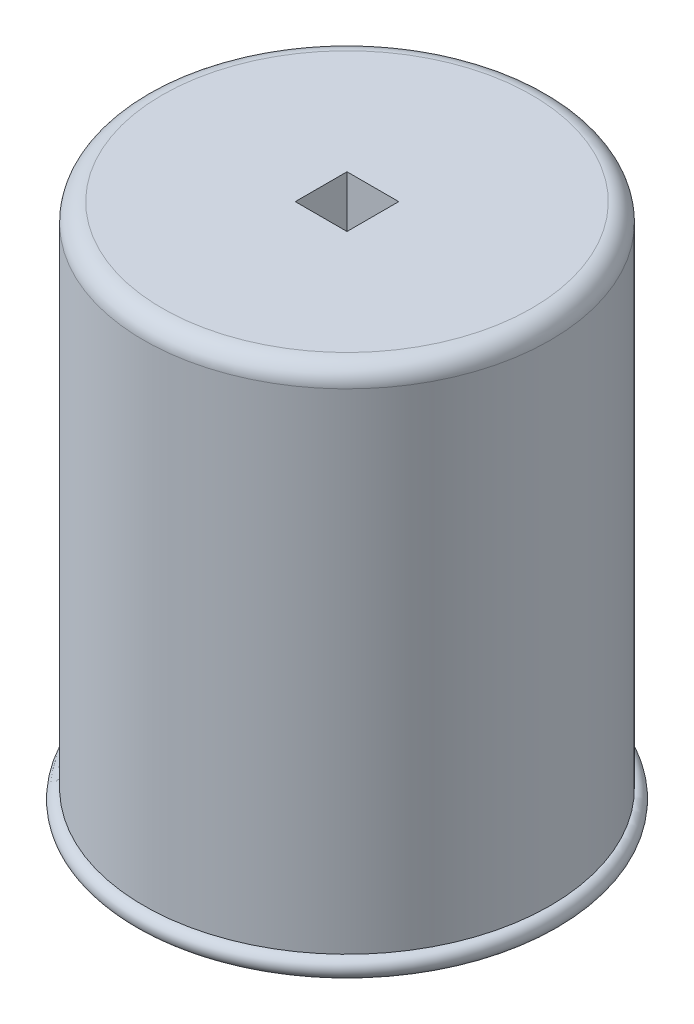
from build123d import *

# Parameters (mm, degrees)
CUT_EXTRUDE2_REACH = 287
SKETCH3_W          = 28
SKETCH3_H          = 28
CUT_EXTRUDE3_DEPTH = 60
CUT_EXTRUDE4_REACH = 191
SKETCH7_W          = 5
SKETCH7_H          = 5
FILLET1_R          = 10


with BuildPart() as part:
    # Sketch1 → Revolve2 (revolve)
    with BuildSketch(Plane.XY):
        with BuildLine():
            Line((0, 0), (0, 40))
            Line((0, 40), (-110, 40))
            Line((-110, 40), (-110, -235))
            ThreePointArc((-110, -235), (-113.535533906, -243.535533906), (-105, -240))
            Line((-105, -240), (-105, 35))
            Line((-105, 35), (-28, 35))
            Line((-28, 35), (-28, -225))
            Line((-28, -225), (-5, -225))
            Line((-5, -225), (-5, -220))
            Line((-5, -220), (-23, -220))
            Line((-23, -220), (-23, -149))
            Line((-23, -149), (-5, -149))
            Line((-5, -149), (-5, -144))
            Line((-5, -144), (-23, -144))
            Line((-23, -144), (-23, 0))
            Line((-23, 0), (0, 0))
        make_face()
    revolve(axis=Axis((0, 0, 0), (0, 1, 0)))

    # Sketch3 → Cut-Extrude2 (cut, up to next)
    with BuildSketch(Plane(origin=(0, 40, 0), x_dir=(1, 0, 0), z_dir=(0, 1, 0)), mode=Mode.PRIVATE) as cut_extrude2_sk1:
        Rectangle(SKETCH3_W, SKETCH3_H)
    cut_extrude2_tool1 = extrude(cut_extrude2_sk1.sketch, amount=-CUT_EXTRUDE2_REACH, mode=Mode.PRIVATE) & part.part
    add(cut_extrude2_tool1.solids().sort_by_distance((0, 40, 0))[0], mode=Mode.SUBTRACT)

    # Sketch6 → Cut-Extrude3 (cut)
    with BuildSketch(Plane(origin=(0, -214.5, 0), x_dir=(1, 0, 0), z_dir=(0, 1, 0))):
        with BuildLine():
            Line((0, -28), (0, -25.5))
            ThreePointArc((0, -25.5), (3.720216095, -25.22716774), (7.360824742, -24.414509193))
            Line((7.360824742, -24.414509193), (6.639175258, -22.02092986))
            ThreePointArc((6.639175258, -22.02092986), (23, 0), (6.639175258, 22.02092986))
            Line((6.639175258, 22.02092986), (7.360824742, 24.414509193))
            ThreePointArc((7.360824742, 24.414509193), (3.720216095, 25.22716774), (0, 25.5))
            Line((0, 25.5), (0, 28))
            ThreePointArc((0, 28), (28, 0), (0, -28))
        make_face()
    extrude(amount=CUT_EXTRUDE3_DEPTH, mode=Mode.SUBTRACT)

    # Sketch7 → Cut-Extrude4 (cut, up to next)
    with BuildSketch(Plane.XZ.offset(149), mode=Mode.PRIVATE) as cut_extrude4_sk1:
        with Locations((14, 0)):
            Rectangle(SKETCH7_W, SKETCH7_H)
    cut_extrude4_tool1 = extrude(cut_extrude4_sk1.sketch, amount=-CUT_EXTRUDE4_REACH, mode=Mode.PRIVATE) & part.part
    add(cut_extrude4_tool1.solids().sort_by_distance((14, -149, 0))[0], mode=Mode.SUBTRACT)

    # Fillet1
    fillet1_edges = [part.edges().sort_by_distance(p)[0] for p in [
        (110, 40, 0),
    ]]
    fillet(fillet1_edges, radius=FILLET1_R)


solid = part.part
